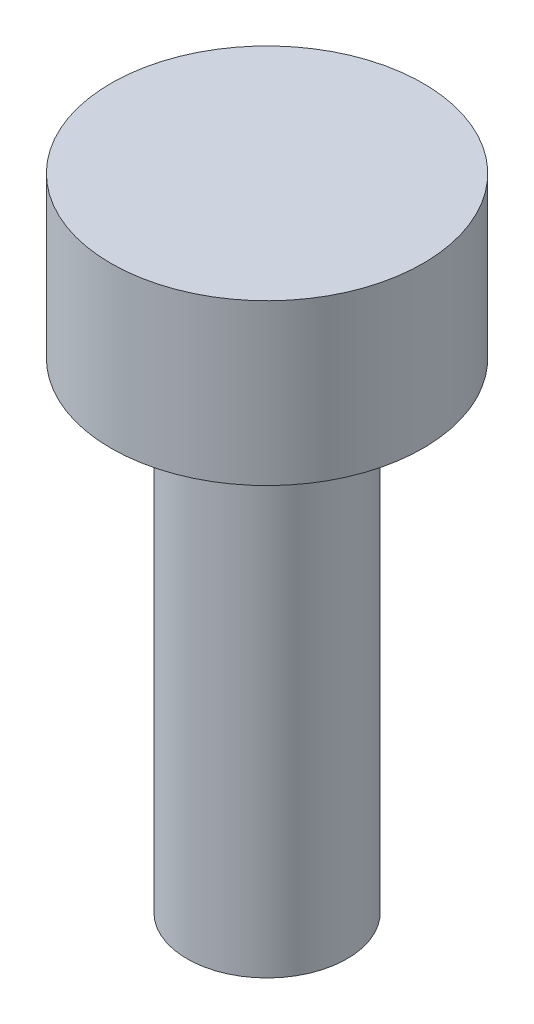
from build123d import *

# Parameters (mm, degrees)
SKETCH1_R           = 1.95
BOSS_EXTRUDE1_DEPTH = 2
SKETCH2_R           = 1
BOSS_EXTRUDE2_DEPTH = 6


with BuildPart() as part:
    # Sketch1 → Boss-Extrude1 (new body)
    with BuildSketch(Plane(origin=(0, 0, 0), x_dir=(1, 0, 0), z_dir=(0, 1, 0))):
        Circle(SKETCH1_R)
    extrude(amount=BOSS_EXTRUDE1_DEPTH)

    # Sketch2 → Boss-Extrude2 (add)
    with BuildSketch(Plane.XZ):
        Circle(SKETCH2_R)
    extrude(amount=BOSS_EXTRUDE2_DEPTH)


solid = part.part
